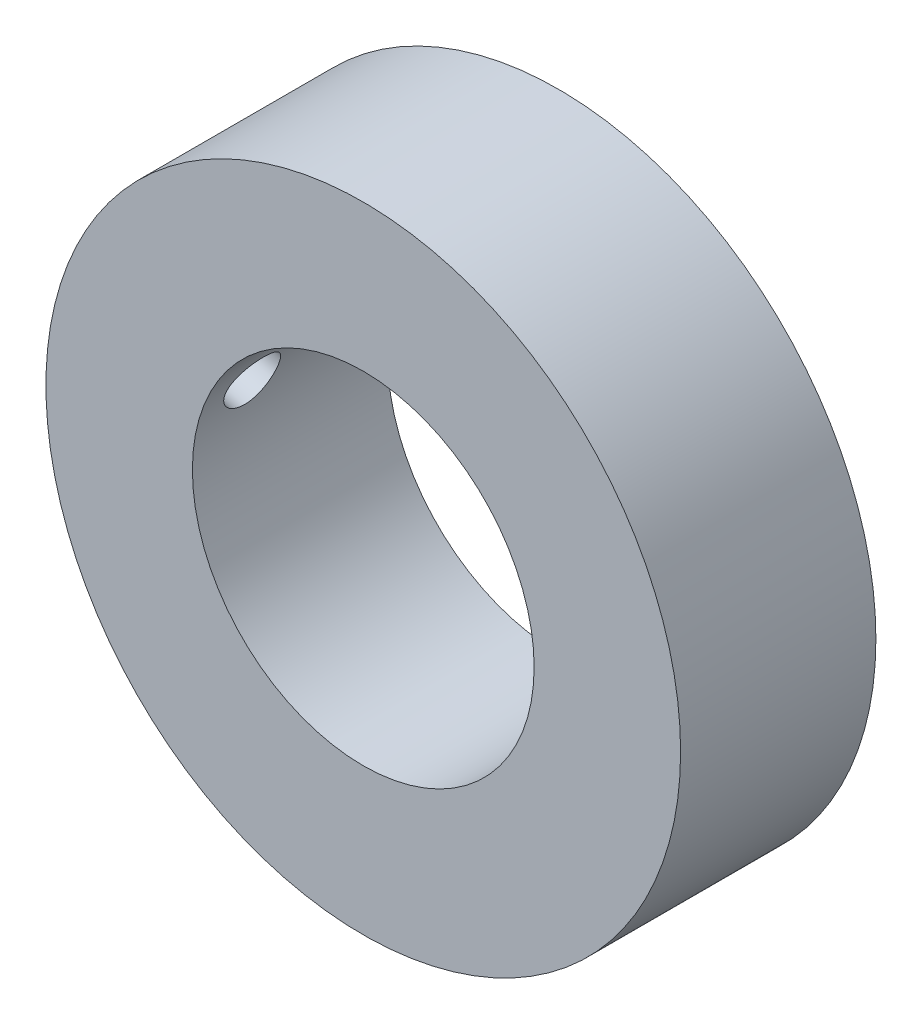
from build123d import *

# Parameters (mm, degrees)
SKIZZE1_R                             = 32.5
SKIZZE1_R_2                           = 17.5
AUFSATZ_LINEAR_AUSTRAGEN1_DEPTH       = 20
F_5_5_5_5_DURCHMESSER_BOHRUNG2_REACH  = 84.262
F_5_5_5_5_DURCHMESSER_BOHRUNG2_BORE_R = 2.75


with BuildPart() as part:
    # Skizze1 → Aufsatz-Linear austragen1 (new body)
    with BuildSketch(Plane.XY):
        Circle(SKIZZE1_R)
        Circle(SKIZZE1_R_2, mode=Mode.SUBTRACT)
    extrude(amount=AUFSATZ_LINEAR_AUSTRAGEN1_DEPTH)

    # Ø5.5 (5.5) Durchmesser Bohrung2 bore → Ø5.5 (5.5) Durchmesser Bohrung2 (cut, up to next)
    with BuildSketch(Plane(origin=(-51.211066257, -27.077970531, 64.793558896), x_dir=(0, 0, -1), z_dir=(-0.965925826, 0.258819045, 0)), mode=Mode.PRIVATE) as f_5_5_5_5_durchmesser_bohrung2_sk1:
        with Locations((49.793558896, -41.065431633)):
            Circle(F_5_5_5_5_DURCHMESSER_BOHRUNG2_BORE_R)
    f_5_5_5_5_durchmesser_bohrung2_tool1 = extrude(f_5_5_5_5_durchmesser_bohrung2_sk1.sketch, amount=-F_5_5_5_5_DURCHMESSER_BOHRUNG2_REACH, mode=Mode.PRIVATE) & part.part
    add(f_5_5_5_5_durchmesser_bohrung2_tool1.solids().sort_by_distance((-40.58255, 12.58819, 15))[0], mode=Mode.SUBTRACT)


solid = part.part
